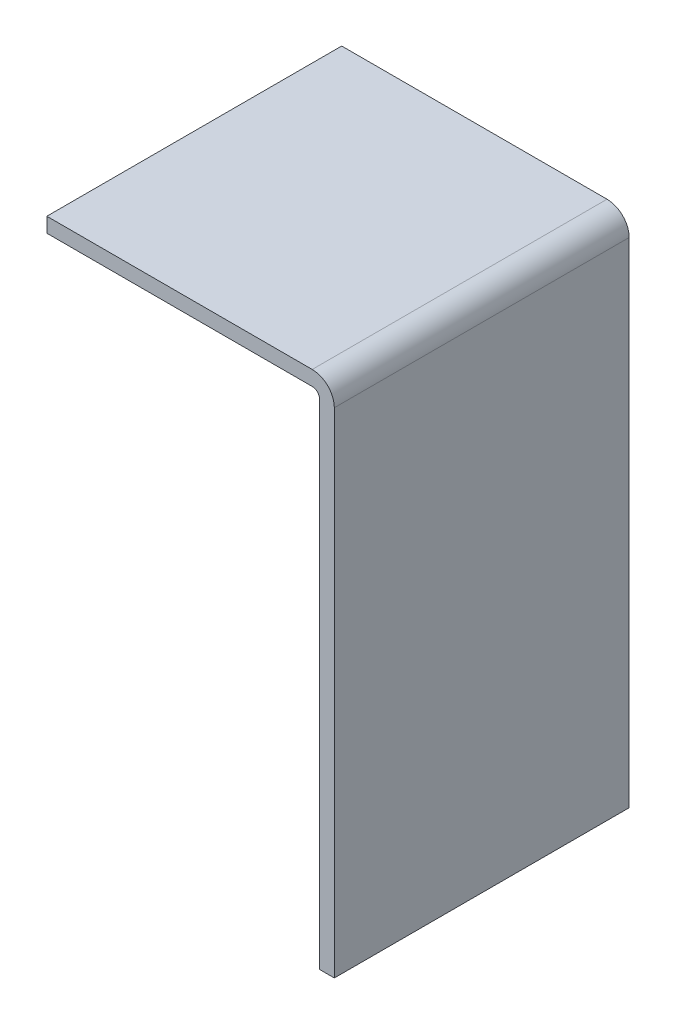
from build123d import *

# Parameters (mm, degrees)
EXTRUSION1_DEPTH = 40


with BuildPart() as part:
    # Esquisse1 → Extrusion1 (new body)
    with BuildSketch(Plane.XY):
        with BuildLine():
            Line((-3, 0), (-39, 0))
            Line((-39, 0), (-39, -2))
            Line((-39, -2), (-3, -2))
            ThreePointArc((-3, -2), (-2.292893219, -2.292893219), (-2, -3))
            Line((-2, -3), (-2, -70))
            Line((-2, -70), (0, -70))
            Line((0, -70), (0, -3))
            ThreePointArc((0, -3), (-0.878679656, -0.878679656), (-3, 0))
        make_face()
    extrude(amount=EXTRUSION1_DEPTH)


solid = part.part
